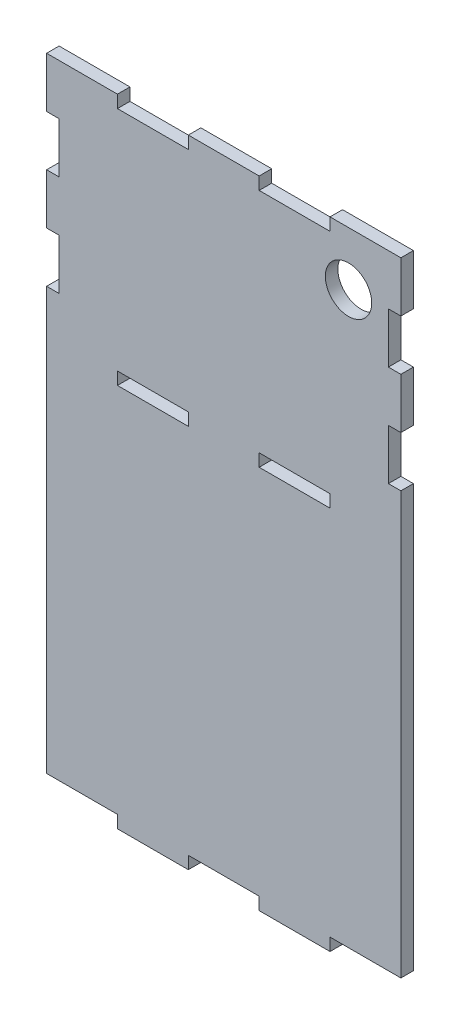
from build123d import *

# Parameters (mm, degrees)
SKETCH1_R           = 5
SKETCH1_W           = 15.28
SKETCH1_H           = 2.7
BOSS_EXTRUDE1_DEPTH = 2.7


with BuildPart() as part:
    # Sketch1 → Boss-Extrude1 (new body)
    with BuildSketch(Plane.XY):
        Polygon((38.2, 27.2), (22.92, 27.2), (22.92, 24.5), (7.64, 24.5), (7.64, 27.2), (-7.64, 27.2), (-7.64, 24.5), (-22.92, 24.5), (-22.92, 27.2), (-38.2, 27.2), (-38.2, 16.32), (-35.5, 16.32), (-35.5, 5.44), (-38.2, 5.44), (-38.2, -5.44), (-35.5, -5.44), (-35.5, -16.32), (-38.2, -16.32), (-38.2, -107.3), (-22.92, -107.3), (-22.92, -110), (-7.64, -110), (-7.64, -107.3), (7.64, -107.3), (7.64, -110), (22.92, -110), (22.92, -107.3), (38.2, -107.3), (38.2, -16.32), (35.5, -16.32), (35.5, -5.44), (38.2, -5.44), (38.2, 5.44), (35.5, 5.44), (35.5, 16.32), (38.2, 16.32), align=None)
        with Locations((26.908058417, 15.599455208)):
            Circle(SKETCH1_R, mode=Mode.SUBTRACT)
        with Locations((-15.28, -25.85)):
            Rectangle(SKETCH1_W, SKETCH1_H, mode=Mode.SUBTRACT)
        with Locations((15.28, -25.85)):
            Rectangle(SKETCH1_W, SKETCH1_H, mode=Mode.SUBTRACT)
    extrude(amount=-BOSS_EXTRUDE1_DEPTH)


solid = part.part
